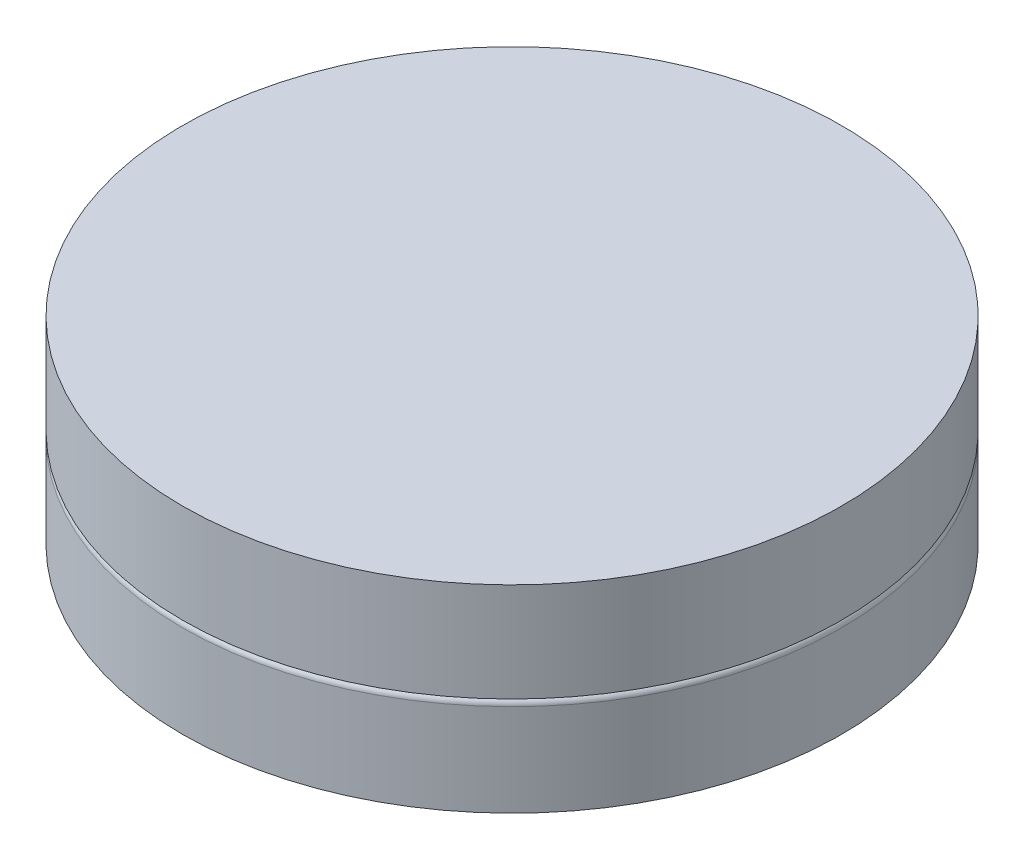
from build123d import *

# Parameters (mm, degrees)
SKETCH1_R           = 2.5
BOSS_EXTRUDE1_DEPTH = 0.75
FILLET1_R           = 0.05
SKETCH2_R           = 2.5
BOSS_EXTRUDE2_DEPTH = 0.75


with BuildPart() as part:
    # Sketch1 → Boss-Extrude1 (new body)
    with BuildSketch(Plane(origin=(0, 0, 0), x_dir=(1, 0, 0), z_dir=(0, 1, 0))):
        Circle(SKETCH1_R)
    extrude(amount=BOSS_EXTRUDE1_DEPTH)

    # Fillet1
    fillet1_edges = [part.edges().sort_by_distance(p)[0] for p in [
        (-2.5, 0.75, 0),
    ]]
    fillet(fillet1_edges, radius=FILLET1_R)

    # Sketch2 → Boss-Extrude2 (add)
    with BuildSketch(Plane(origin=(0, 0.75, 0), x_dir=(1, 0, 0), z_dir=(0, 1, 0))):
        Circle(SKETCH2_R)
    extrude(amount=BOSS_EXTRUDE2_DEPTH)


solid = part.part
